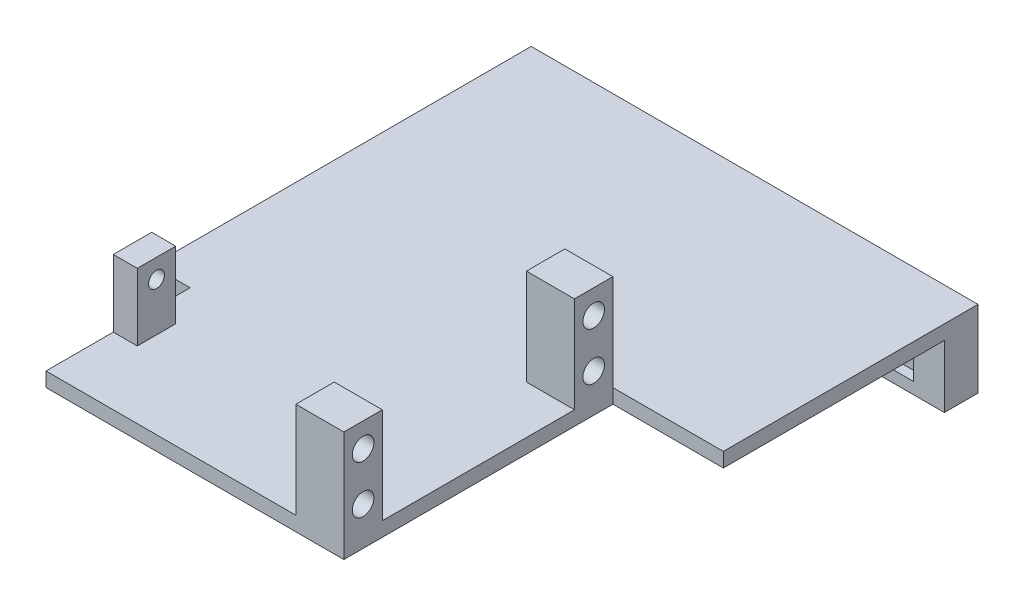
from build123d import *

# Parameters (mm, degrees)
ESQUISSE2_W             = 8
ESQUISSE2_H             = 20
ESQUISSE2_R             = 2.25
BOSS_EXTRU_1_DEPTH      = 10
BOSS_EXTRU_1_2_DEPTH    = 10
BOSS_EXTRU_2_DEPTH      = 3
BOSS_EXTRU_5_DEPTH      = 93
ENL_V_MAT_EXTRU_1_REACH = 18
ESQUISSE8_W             = 8
ESQUISSE8_H             = 30
ESQUISSE9_W             = 80.2
ESQUISSE9_H             = 8.2
ENL_V_MAT_EXTRU_2_DEPTH = 2
ESQUISSE10_W            = 8
ESQUISSE10_H            = 14
ESQUISSE10_R            = 1.65
BOSS_EXTRU_6_DEPTH      = 5


with BuildPart() as part:
    # Esquisse2 → Boss.-Extru.1 (new body)
    with BuildSketch(Plane(origin=(0, 0, 0), x_dir=(0, 0, -1), z_dir=(1, 0, 0))):
        with Locations((-24, 0)):
            Rectangle(ESQUISSE2_W, ESQUISSE2_H)
        with Locations((-24, 5)):
            Circle(ESQUISSE2_R, mode=Mode.SUBTRACT)
        with Locations((-24, -5)):
            Circle(ESQUISSE2_R, mode=Mode.SUBTRACT)
    extrude(amount=BOSS_EXTRU_1_DEPTH)



with BuildPart() as body_2:
    # Esquisse2 → Boss.-Extru.1 2 (new body)
    with BuildSketch(Plane(origin=(0, 0, 0), x_dir=(0, 0, -1), z_dir=(1, 0, 0))):
        with Locations((24, 0)):
            Rectangle(ESQUISSE2_W, ESQUISSE2_H)
        with Locations((24, 5)):
            Circle(ESQUISSE2_R, mode=Mode.SUBTRACT)
        with Locations((24, -5)):
            Circle(ESQUISSE2_R, mode=Mode.SUBTRACT)
    extrude(amount=BOSS_EXTRU_1_2_DEPTH)


with BuildPart() as part_1:
    add(part.part)

    add(body_2.part)  # Boss.-Extru.2 merges body 2
    # Esquisse3 → Boss.-Extru.2 (add)
    with BuildSketch(Plane.XZ.offset(10)):
        Polygon((-60, 28), (-60, -72), (33, -72), (33, -28), (10, -28), (10, 28), align=None)
    extrude(amount=BOSS_EXTRU_2_DEPTH)

    # Esquisse7 → Boss.-Extru.5 (add)
    with BuildSketch(Plane(origin=(33, 0, 0), x_dir=(0, 0, -1), z_dir=(1, 0, 0))):
        Polygon((72, -10), (81, -10), (81, -26), (74, -26), (74, -13), (72, -13), align=None)
    extrude(amount=-BOSS_EXTRU_5_DEPTH)

    # Esquisse8 → Enlèv. mat.-Extru.1 (cut, up to next)
    with BuildSketch(Plane(origin=(0, -10, 0), x_dir=(1, 0, 0), z_dir=(0, 1, 0)), mode=Mode.PRIVATE) as enl_v_mat_extru_1_sk1:
        with Locations((-56, -13)):
            Rectangle(ESQUISSE8_W, ESQUISSE8_H)
    enl_v_mat_extru_1_tool1 = extrude(enl_v_mat_extru_1_sk1.sketch, amount=-ENL_V_MAT_EXTRU_1_REACH, mode=Mode.PRIVATE) & part_1.part
    add(enl_v_mat_extru_1_tool1.solids().sort_by_distance((-56, -10, 13))[0], mode=Mode.SUBTRACT)

    # Esquisse9 → Enlèv. mat.-Extru.2 (cut)
    with BuildSketch(Plane.XY.offset(-74)):
        with Locations((-13.5, -19.5)):
            Rectangle(ESQUISSE9_W, ESQUISSE9_H)
    extrude(amount=-ENL_V_MAT_EXTRU_2_DEPTH, mode=Mode.SUBTRACT)

    # Esquisse10 → Boss.-Extru.6 (add)
    with BuildSketch(Plane.ZY.offset(52)):
        with Locations((10, -3)):
            Rectangle(ESQUISSE10_W, ESQUISSE10_H)
        with Locations((10, 0)):
            Circle(ESQUISSE10_R, mode=Mode.SUBTRACT)
    extrude(amount=-BOSS_EXTRU_6_DEPTH)


solid = part_1.part
